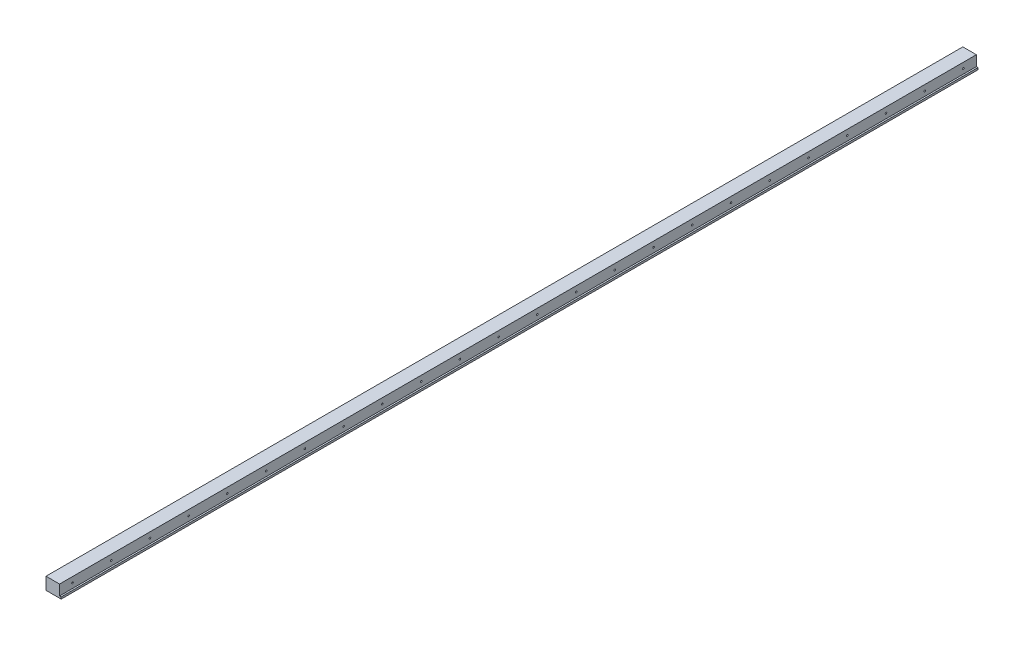
from build123d import *

# Parameters (mm, degrees)
SKETCH1_W           = 1420
SKETCH1_H           = 19
BOSS_EXTRUDE1_DEPTH = 23.5
SKETCH2_W           = 1420
SKETCH2_H           = 16
CUT_EXTRUDE1_DEPTH  = 2.5
LPATTERN1_COUNT     = 24
LPATTERN1_PITCH     = 60
LPATTERN2_COUNT     = 24
LPATTERN2_PITCH     = 60


with BuildPart() as part:
    # Sketch1 → Boss-Extrude1 (new body)
    with BuildSketch(Plane(origin=(0, 0, 0), x_dir=(0, 0, -1), z_dir=(1, 0, 0))):
        with Locations((710, 9.5)):
            Rectangle(SKETCH1_W, SKETCH1_H)
    extrude(amount=BOSS_EXTRUDE1_DEPTH)

    # Sketch2 → Cut-Extrude1 (cut)
    with BuildSketch(Plane.ZY.offset(-23.5)):
        with Locations((-710, 11)):
            Rectangle(SKETCH2_W, SKETCH2_H)
    extrude(amount=CUT_EXTRUDE1_DEPTH, mode=Mode.SUBTRACT)

    # Sketch3 → M4x0.7 Tapped Hole1 (revolve, cut)
    with BuildSketch(Plane(origin=(0, 10.5, -28), x_dir=(0, 0, 1), z_dir=(0, 1, 0))):
        Polygon((0, 0), (0, 11.591420021), (1.65, 10.6), (1.65, 0), align=None)
    m4x0_7_tapped_hole1 = revolve(axis=Axis((-6.35, 10.5, -28), (1, 0, 0)), mode=Mode.SUBTRACT)

    # LPattern1: M4x0.7 Tapped Hole1 ×24
    with Locations(*[(0, 0, -i * LPATTERN1_PITCH) for i in range(1, LPATTERN1_COUNT)]):
        add(m4x0_7_tapped_hole1, mode=Mode.SUBTRACT)

    # Sketch5 → M3x0.5 Tapped Hole1 (revolve, cut)
    with BuildSketch(Plane(origin=(21, 10.5, -20), x_dir=(0, 0, -1), z_dir=(0, 1, 0))):
        Polygon((0, 0), (0, 10.751075774), (1.25, 10), (1.25, 0), align=None)
    m3x0_5_tapped_hole1 = revolve(axis=Axis((27.35, 10.5, -20), (-1, 0, 0)), mode=Mode.SUBTRACT)

    # LPattern2: M3x0.5 Tapped Hole1 ×24
    with Locations(*[(0, 0, -i * LPATTERN2_PITCH) for i in range(1, LPATTERN2_COUNT)]):
        add(m3x0_5_tapped_hole1, mode=Mode.SUBTRACT)


solid = part.part
